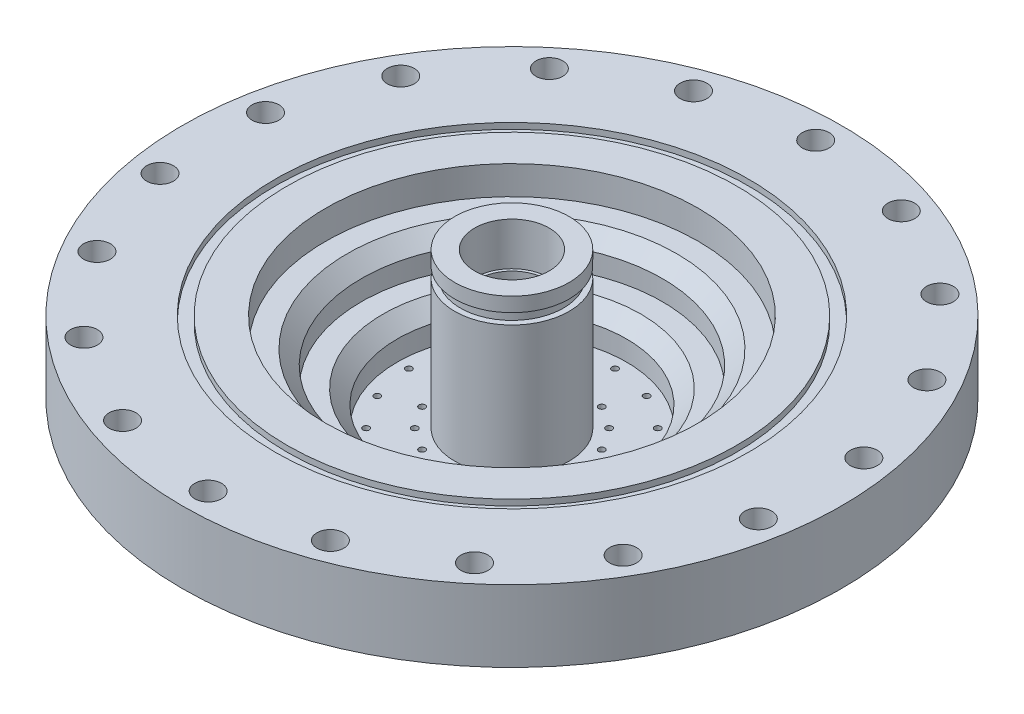
from build123d import *

# Parameters (mm, degrees)
SKETCH1_R           = 38.0746
BOSS_EXTRUDE1_DEPTH = 4.445
SKETCH2_R           = 28.575
SKETCH2_R_2         = 7.62
BOSS_EXTRUDE2_DEPTH = 5.08
SKETCH4_R           = 38.0746
SKETCH4_R_2         = 7.62
BOSS_EXTRUDE3_DEPTH = 25.4
SKETCH5_R           = 73.025
SKETCH5_R_2         = 38.0746
BOSS_EXTRUDE4_DEPTH = 19.05
SKETCH6_R           = 41.275
SKETCH6_R_2         = 12.6746
CUT_EXTRUDE1_DEPTH  = 9.525
SKETCH7_R           = 33.3375
SKETCH7_R_2         = 12.6746
CUT_EXTRUDE2_DEPTH  = 7.62
SKETCH8_R           = 25.4
SKETCH8_R_2         = 12.6746
CUT_EXTRUDE3_DEPTH  = 7.62
SKETCH10_R          = 12.6746
SKETCH10_R_2        = 8.255
BOSS_EXTRUDE5_DEPTH = 9.525
CHAMFER1_SIZE       = 3.175
SKETCH12_R          = 0.6985
CUT_EXTRUDE5_DEPTH  = 10.16
CUT_EXTRUDE6_START  = 8.411991
SKETCH14_R          = 0.508
CUT_EXTRUDE6_DEPTH  = 5.719232
CUT_EXTRUDE7_START  = 8.411991
SKETCH15_R          = 0.508
CUT_EXTRUDE7_DEPTH  = 5.719232
CIRPATTERN2_COUNT   = 16
SKETCH16_W          = 1.27
SKETCH16_H          = 2.3622
SKETCH17_R          = 2.97688
CUT_EXTRUDE8_DEPTH  = 35.925000419
CIRPATTERN3_COUNT   = 18
SKETCH20_R          = 86.430986252
SKETCH20_R_2        = 37.221288793
CUT_EXTRUDE11_DEPTH = 3.175
SKETCH18_R          = 52.4383
SKETCH18_R_2        = 49.7967
CUT_EXTRUDE9_DEPTH  = 1.3208
SKETCH19_R          = 0.79375
CUT_EXTRUDE10_DEPTH = 86.868315867
CIRPATTERN4_COUNT   = 16


with BuildPart() as part:
    # Sketch1 → Boss-Extrude1 (new body)
    with BuildSketch(Plane(origin=(0, 0, 0), x_dir=(1, 0, 0), z_dir=(0, 1, 0))):
        Circle(SKETCH1_R)
    extrude(amount=BOSS_EXTRUDE1_DEPTH)

    # Sketch2 → Boss-Extrude2 (add)
    with BuildSketch(Plane(origin=(0, 4.445, 0), x_dir=(1, 0, 0), z_dir=(0, 1, 0))):
        Circle(SKETCH2_R)
        Circle(SKETCH2_R_2, mode=Mode.SUBTRACT)
    extrude(amount=BOSS_EXTRUDE2_DEPTH)

    # Sketch4 → Boss-Extrude3 (add)
    with BuildSketch(Plane(origin=(0, 9.525, 0), x_dir=(1, 0, 0), z_dir=(0, 1, 0))):
        Circle(SKETCH4_R)
        Circle(SKETCH4_R_2, mode=Mode.SUBTRACT)
    extrude(amount=BOSS_EXTRUDE3_DEPTH)

    # Sketch5 → Boss-Extrude4 (add)
    with BuildSketch(Plane(origin=(0, 34.925, 0), x_dir=(1, 0, 0), z_dir=(0, 1, 0))):
        Circle(SKETCH5_R)
        Circle(SKETCH5_R_2, mode=Mode.SUBTRACT)
    extrude(amount=-BOSS_EXTRUDE4_DEPTH)

    # Sketch6 → Cut-Extrude1 (cut)
    with BuildSketch(Plane(origin=(0, 34.925, 0), x_dir=(1, 0, 0), z_dir=(0, 1, 0))):
        Circle(SKETCH6_R)
        Circle(SKETCH6_R_2, mode=Mode.SUBTRACT)
    extrude(amount=-CUT_EXTRUDE1_DEPTH, mode=Mode.SUBTRACT)

    # Sketch7 → Cut-Extrude2 (cut)
    with BuildSketch(Plane(origin=(0, 25.4, 0), x_dir=(1, 0, 0), z_dir=(0, 1, 0))):
        Circle(SKETCH7_R)
        Circle(SKETCH7_R_2, mode=Mode.SUBTRACT)
    extrude(amount=-CUT_EXTRUDE2_DEPTH, mode=Mode.SUBTRACT)

    # Sketch8 → Cut-Extrude3 (cut)
    with BuildSketch(Plane(origin=(0, 17.78, 0), x_dir=(1, 0, 0), z_dir=(0, 1, 0))):
        Circle(SKETCH8_R)
        Circle(SKETCH8_R_2, mode=Mode.SUBTRACT)
    extrude(amount=-CUT_EXTRUDE3_DEPTH, mode=Mode.SUBTRACT)

    # Sketch10 → Boss-Extrude5 (add)
    with BuildSketch(Plane(origin=(0, 34.925, 0), x_dir=(1, 0, 0), z_dir=(0, 1, 0))):
        Circle(SKETCH10_R)
        Circle(SKETCH10_R_2, mode=Mode.SUBTRACT)
    extrude(amount=BOSS_EXTRUDE5_DEPTH)

    # Chamfer1
    chamfer1_edges = [part.edges().sort_by_distance(p)[0] for p in [
        (-33.3375, 25.4, 0),
        (-25.4, 17.78, 0),
    ]]
    chamfer(chamfer1_edges, length=CHAMFER1_SIZE)

    # Sketch12 → Cut-Extrude5 (cut)
    with BuildSketch(Plane.XZ):
        with Locations((5.828207446, 14.070537459)):
            Circle(SKETCH12_R)
        with Locations((8.742311168, 21.105806189)):
            Circle(SKETCH12_R)
    cut_extrude5 = extrude(amount=-CUT_EXTRUDE5_DEPTH, mode=Mode.SUBTRACT)

    # Sketch14 → Cut-Extrude6 (cut)
    with BuildSketch(Plane(origin=(2.394210183, -10.836355406, 5.780134695), x_dir=(-0.331413574, -0.5, -0.800103145), z_dir=(-0.191341716, 0.866025404, -0.461939766)).offset(CUT_EXTRUDE6_START)):
        with Locations((-6.594714168, 0)):
            Circle(SKETCH14_R)
    cut_extrude6 = extrude(amount=CUT_EXTRUDE6_DEPTH, mode=Mode.SUBTRACT)

    # Sketch15 → Cut-Extrude7 (cut)
    with BuildSketch(Plane(origin=(1.24841947, 5.650430014, 3.013951217), x_dir=(-0.331413574, 0.5, -0.800103145), z_dir=(0.191341716, 0.866025404, 0.461939766)).offset(CUT_EXTRUDE7_START)):
        with Locations((-26.378856671, 0)):
            Circle(SKETCH15_R)
    cut_extrude7 = extrude(amount=CUT_EXTRUDE7_DEPTH, mode=Mode.SUBTRACT)

    # CirPattern2: Cut-Extrude5, Cut-Extrude6, Cut-Extrude7 ×16 about axis
    cirpattern2_axis = Axis((0, 0, 0), (0, 1, 0))
    for i in range(1, CIRPATTERN2_COUNT):
        add(cut_extrude5.rotate(cirpattern2_axis, i * 360 / CIRPATTERN2_COUNT), mode=Mode.SUBTRACT)
        add(cut_extrude6.rotate(cirpattern2_axis, i * 360 / CIRPATTERN2_COUNT), mode=Mode.SUBTRACT)
        add(cut_extrude7.rotate(cirpattern2_axis, i * 360 / CIRPATTERN2_COUNT), mode=Mode.SUBTRACT)

    # Sketch16 → Cut-Revolve2 (revolve, cut)
    with BuildSketch(Plane.XY):
        with Locations((-12.065, 40.0939)):
            Rectangle(SKETCH16_W, SKETCH16_H)
    revolve(axis=Axis((0, 0, 0), (0, 1, 0)), mode=Mode.SUBTRACT)

    # Sketch17 → Cut-Extrude8 (cut, through all)
    with BuildSketch(Plane(origin=(0, 34.925, 0), x_dir=(1, 0, 0), z_dir=(0, 1, 0))):
        with Locations((0, 67.31)):
            Circle(SKETCH17_R)
    cut_extrude8 = extrude(amount=-CUT_EXTRUDE8_DEPTH, mode=Mode.SUBTRACT)

    # CirPattern3: Cut-Extrude8 ×18 about axis
    cirpattern3_axis = Axis((0, 0, 0), (0, 1, 0))
    for i in range(1, CIRPATTERN3_COUNT):
        add(cut_extrude8.rotate(cirpattern3_axis, i * 360 / CIRPATTERN3_COUNT), mode=Mode.SUBTRACT)

    # Sketch20 → Cut-Extrude11 (cut)
    with BuildSketch(Plane(origin=(0, 34.925, 0), x_dir=(1, 0, 0), z_dir=(0, 1, 0))):
        Circle(SKETCH20_R)
        Circle(SKETCH20_R_2, mode=Mode.SUBTRACT)
    extrude(amount=-CUT_EXTRUDE11_DEPTH, mode=Mode.SUBTRACT)

    # Sketch18 → Cut-Extrude9 (cut)
    with BuildSketch(Plane(origin=(0, 31.75, 0), x_dir=(1, 0, 0), z_dir=(0, 1, 0))):
        Circle(SKETCH18_R)
        Circle(SKETCH18_R_2, mode=Mode.SUBTRACT)
    extrude(amount=-CUT_EXTRUDE9_DEPTH, mode=Mode.SUBTRACT)

    # Sketch19 → Cut-Extrude10 (cut, through all)
    with BuildSketch(Plane(origin=(0, 0, 0), x_dir=(0, 1, 0), z_dir=(0.98078528, 0, -0.195090322))):
        with Locations((6.35, 0)):
            Circle(SKETCH19_R)
    cut_extrude10 = extrude(amount=-CUT_EXTRUDE10_DEPTH, mode=Mode.SUBTRACT)

    # CirPattern4: Cut-Extrude10 ×16 about axis
    cirpattern4_axis = Axis((0, 15.875, 0), (0, 1, 0))
    for i in range(1, CIRPATTERN4_COUNT):
        add(cut_extrude10.rotate(cirpattern4_axis, i * 360 / CIRPATTERN4_COUNT), mode=Mode.SUBTRACT)


solid = part.part
